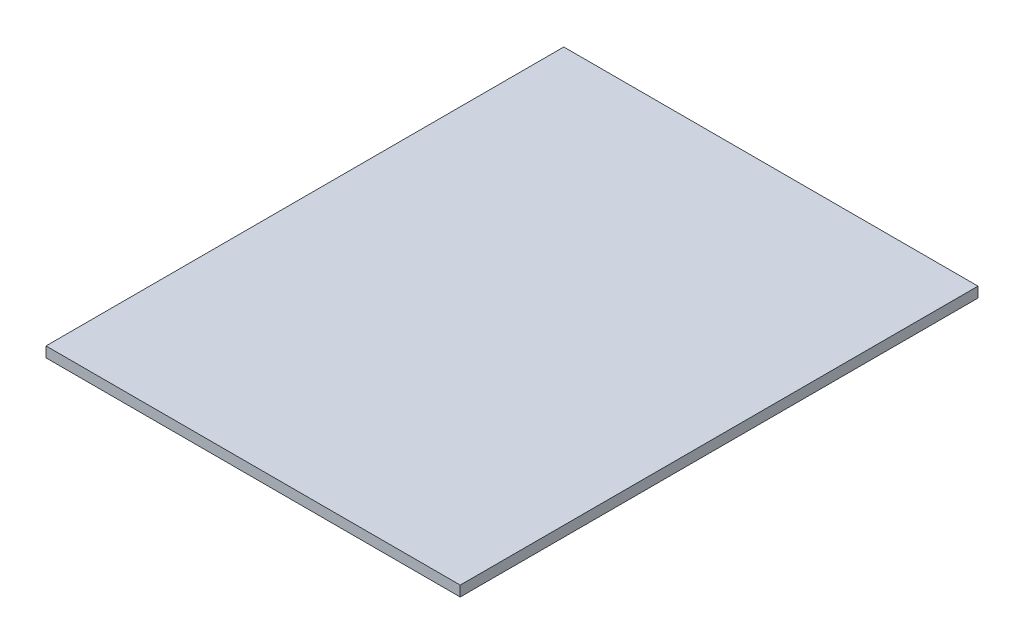
from build123d import *

# Parameters (mm, degrees)
SKETCH1_W           = 120
SKETCH1_H           = 150
BOSS_EXTRUDE1_DEPTH = 3
SKETCH2_W           = 100
SKETCH2_H           = 130
CUT_EXTRUDE1_DEPTH  = 0.18


with BuildPart() as part:
    # Sketch1 → Boss-Extrude1 (new body)
    with BuildSketch(Plane(origin=(0, 0, 0), x_dir=(1, 0, 0), z_dir=(0, 1, 0))):
        Rectangle(SKETCH1_W, SKETCH1_H)
    extrude(amount=BOSS_EXTRUDE1_DEPTH)

    # Sketch2 → Cut-Extrude1 (cut)
    with BuildSketch(Plane.XZ):
        Rectangle(SKETCH2_W, SKETCH2_H)
    extrude(amount=-CUT_EXTRUDE1_DEPTH, mode=Mode.SUBTRACT)


solid = part.part
